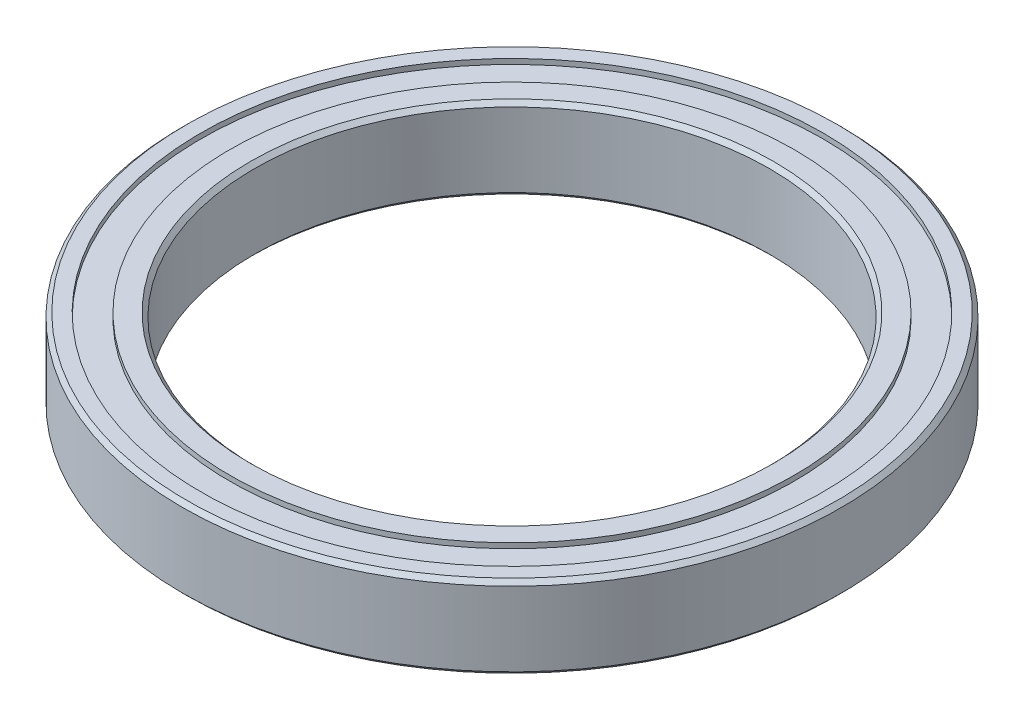
from build123d import *

# Parameters (mm, degrees)
FASE1_SIZE = 0.2


with BuildPart() as part:
    # Skizze2 → Rotation2 (revolve)
    with BuildSketch(Plane(origin=(0, 0, 0), x_dir=(0, 0, -1), z_dir=(1, 0, 0))):
        Polygon((-16, 2), (-16, -2), (-15.1, -2), (-15.1, -1.75), (-13.7, -1.75), (-13.7, -2), (-12.5, -2), (-12.5, 2), (-13.7, 2), (-13.7, 1.75), (-15.1, 1.75), (-15.1, 2), align=None)
    revolve(axis=Axis((0, -18.122913865, 0), (0, 1, 0)))

    # Fase1
    fase1_edges = [part.edges().sort_by_distance(p)[0] for p in [
        (0, 2, -12.5),
        (0, -2, -12.5),
        (0, 2, -16),
        (0, -2, -16),
    ]]
    chamfer(fase1_edges, length=FASE1_SIZE)


solid = part.part
